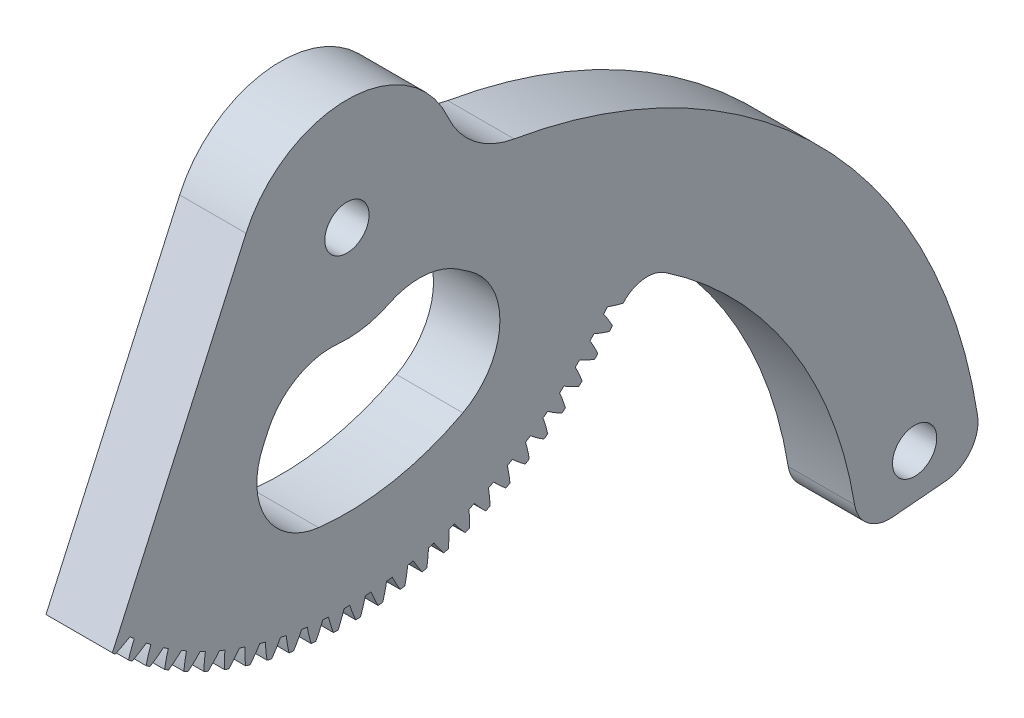
from build123d import *

# Parameters (mm, degrees)
BASPROSKE_W             = 12.7
BASPROSKE_H             = 49
TOOTHCUT_DEPTH          = 71.450621005
TEETHCUTS_COUNT         = 96
TEETHCUTS_ANGLE         = 356.25
BORSKE_R                = 0.4
BORE_DEPTH              = 50.0000508
CORTAR_EXTRUIR1_DEPTH   = 71.427720324
SALIENTE_EXTRUIR1_DEPTH = 12.7
CROQUIS4_R              = 3.175
CORTAR_EXTRUIR2_DEPTH   = 119.085472642
CROQUIS5_R              = 5
CORTAR_EXTRUIR3_DEPTH   = 6
CORTAR_EXTRUIR4_REACH   = 120.085
CORTAR_EXTRUIR5_DEPTH   = 1.5875


with BuildPart() as part:
    # BasProSke → Base-Revolve (revolve)
    with BuildSketch(Plane(origin=(0, 0, 0), x_dir=(1, 0, 0), z_dir=(0, 1, 0)), mode=Mode.PRIVATE) as base_revolve_sk:
        with Locations((6.35, 24.5)):
            Rectangle(BASPROSKE_W, BASPROSKE_H)
    revolve(base_revolve_sk.sketch.rotate(Axis((-10, 0, 0), (1, 0, 0)), 180), axis=Axis((-10, 0, 0), (1, 0, 0)))

    # TooCutSke → ToothCut (cut, through all)
    with BuildSketch(Plane(origin=(0, 0, 0), x_dir=(0, 0, -1), z_dir=(1, 0, 0))):
        with BuildLine():
            ThreePointArc((0.415666164, 46.747152027), (0, 46.749), (-0.415666164, 46.747152027))
            ThreePointArc((-0.415666164, 46.747152027), (-0.812912529, 47.891564186), (-1.28153738, 49.008647269))
            ThreePointArc((-1.28153738, 49.008647269), (0, 49.0254), (1.28153738, 49.008647269))
            ThreePointArc((1.28153738, 49.008647269), (0.812912529, 47.891564186), (0.415666164, 46.747152027))
        make_face()
    toothcut = extrude(amount=TOOTHCUT_DEPTH, mode=Mode.SUBTRACT)

    # TeethCuts: ToothCut ×96 about axis
    teethcuts_axis = Axis((-10, 0, 0), (1, 0, 0))
    for i in range(1, TEETHCUTS_COUNT):
        add(toothcut.rotate(teethcuts_axis, i * TEETHCUTS_ANGLE / (TEETHCUTS_COUNT - 1)), mode=Mode.SUBTRACT)

    # BorSke → Bore (cut, symmetric)
    with BuildSketch(Plane(origin=(0, 0, 0), x_dir=(0, 0, -1), z_dir=(1, 0, 0))):
        with Locations(Location((0, 0, 0), (0, 0, 180))):
            Circle(BORSKE_R)
    extrude(amount=BORE_DEPTH, both=True, mode=Mode.SUBTRACT)

    # Croquis2 → Cortar-Extruir1 (cut, through all)
    with BuildSketch(Plane(origin=(12.7, 0, 0), x_dir=(0, 0, -1), z_dir=(1, 0, 0))):
        with BuildLine():
            ThreePointArc((23.984655986, -0.583157257), (36.524600052, -3.793553196), (48.395867777, -8.953964212))
            ThreePointArc((48.395867777, -8.953964212), (-15.236757781, 47.277477286), (-33.647532421, -35.62083045))
            Line((-33.647532421, -35.62083045), (-14.472949427, 6.922987037))
            ThreePointArc((-14.472949427, 6.922987037), (0.063742892, 16.274872026), (14.524865824, 6.806551162))
            ThreePointArc((14.524865824, 6.806551162), (18.326573639, 1.923496246), (23.984655986, -0.583157257))
        make_face()
    extrude(amount=-CORTAR_EXTRUIR1_DEPTH, mode=Mode.SUBTRACT)

    # Croquis3 → Saliente-Extruir1 (add, through all)
    with BuildSketch(Plane(origin=(12.7, 0, 0), x_dir=(0, 0, -1), z_dir=(1, 0, 0))):
        with BuildLine():
            Line((78.291342391, -74.718112999), (85.901159176, -74.052340298))
            ThreePointArc((85.901159176, -74.052340298), (89.456654772, -72.12542661), (90.47830187, -68.212527108))
            ThreePointArc((90.47830187, -68.212527108), (68.118235351, -23.693910917), (23.984655986, -0.583157257))
            Line((23.984655986, -0.583157257), (26.101585902, -24.779776923))
            Line((26.101585902, -24.779776923), (39.634428828, -28.811665198))
            ThreePointArc((39.634428828, -28.811665198), (42.509448117, -27.287465547), (45.67542899, -28.039453308))
            ThreePointArc((45.67542899, -28.039453308), (63.643556946, -46.447865582), (72.834621498, -70.473843129))
            ThreePointArc((72.834621498, -70.473843129), (74.729702565, -73.667298489), (78.291342391, -74.718112999))
        make_face()
    extrude(amount=-SALIENTE_EXTRUIR1_DEPTH)

    # Croquis4 → Cortar-Extruir2 (cut, through all)
    with BuildSketch(Plane(origin=(12.7, 0, 0), x_dir=(0, 0, -1), z_dir=(1, 0, 0))):
        with Locations((0, 0.4)):
            Circle(CROQUIS4_R)
        with Locations((81.443110483, -68.068113052)):
            Circle(CROQUIS4_R)
    extrude(amount=-CORTAR_EXTRUIR2_DEPTH, mode=Mode.SUBTRACT)

    # Croquis5 → Cortar-Extruir3 (cut)
    with BuildSketch(Plane(origin=(0, 0, 0), x_dir=(0, 0, -1), z_dir=(1, 0, 0))):
        with Locations((81.443110483, -68.068113052)):
            Circle(CROQUIS5_R)
    extrude(amount=CORTAR_EXTRUIR3_DEPTH, mode=Mode.SUBTRACT)

    # Croquis7 → Cortar-Extruir4 (cut, up to next)
    with BuildSketch(Plane(origin=(12.7, 0, 0), x_dir=(0, 0, -1), z_dir=(1, 0, 0)), mode=Mode.PRIVATE) as cortar_extruir4_sk1:
        with BuildLine():
            Line((-12.043509039, -20.805573528), (-11.34750433, -19.261305404))
            ThreePointArc((-11.34750433, -19.261305404), (-7.259201746, -14.726545988), (-1.296355861, -13.414017916))
            ThreePointArc((-1.296355861, -13.414017916), (2.472528728, -13.252627263), (6.05863919, -12.082007878))
            ThreePointArc((6.05863919, -12.082007878), (11.144271121, -11.104114667), (16.037079993, -12.801273654))
            Line((16.037079993, -12.801273654), (17.558094048, -13.832517981))
            ThreePointArc((17.558094048, -13.832517981), (21.931785996, -22.648631071), (16.634261829, -30.942560718))
            ThreePointArc((16.634261829, -30.942560718), (6.576209725, -34.468441958), (-4.075170629, -34.848372491))
            ThreePointArc((-4.075170629, -34.848372491), (-11.624054462, -29.849707406), (-12.043509039, -20.805573528))
        make_face()
    cortar_extruir4_tool1 = extrude(cortar_extruir4_sk1.sketch, amount=-CORTAR_EXTRUIR4_REACH, mode=Mode.PRIVATE) & part.part
    add(cortar_extruir4_tool1.solids().sort_by_distance((12.7, -23.348546, -4.438761))[0], mode=Mode.SUBTRACT)

    # Croquis11 → Cortar-Extruir5 (cut)
    with BuildSketch(Plane(origin=(12.7, 0, 0), x_dir=(0, 0, -1), z_dir=(1, 0, 0))):
        with BuildLine():
            Line((78.291342391, -74.718112999), (85.901159176, -74.052340298))
            ThreePointArc((85.901159176, -74.052340298), (89.456654772, -72.12542661), (90.47830187, -68.212527108))
            ThreePointArc((90.47830187, -68.212527108), (68.118235351, -23.693910917), (23.984655986, -0.583157257))
            ThreePointArc((23.984655986, -0.583157257), (18.326573639, 1.923496246), (14.524865824, 6.806551162))
            ThreePointArc((14.524865824, 6.806551162), (0.063742892, 16.274872026), (-14.472949427, 6.922987037))
            Line((-14.472949427, 6.922987037), (-33.647532421, -35.62083045))
            ThreePointArc((-33.647532421, -35.62083045), (-33.450270144, -35.806136727), (-33.251987351, -35.990350613))
            ThreePointArc((-33.251987351, -35.990350613), (-32.176077274, -35.46435344), (-31.135053426, -34.872302035))
            ThreePointArc((-31.135053426, -34.872302035), (-30.82375751, -35.14775916), (-30.510024688, -35.420437526))
            ThreePointArc((-30.510024688, -35.420437526), (-30.961130133, -36.529833486), (-31.342192881, -37.665195411))
            ThreePointArc((-31.342192881, -37.665195411), (-31.085270924, -37.877512215), (-30.826910741, -38.088076535))
            ThreePointArc((-30.826910741, -38.088076535), (-29.787706131, -37.492837677), (-28.78763321, -36.833967682))
            ThreePointArc((-28.78763321, -36.833967682), (-28.458988045, -37.088475305), (-28.12809293, -37.340050738))
            ThreePointArc((-28.12809293, -37.340050738), (-28.505674557, -38.476575104), (-28.811665198, -39.634428828))
            ThreePointArc((-28.811665198, -39.634428828), (-28.541407147, -39.829487545), (-28.269828567, -40.022703467))
            ThreePointArc((-28.269828567, -40.022703467), (-27.271779458, -39.360771828), (-26.316939929, -38.637904625))
            ThreePointArc((-26.316939929, -38.637904625), (-25.972352823, -38.870372906), (-25.62571236, -39.09976812))
            ThreePointArc((-25.62571236, -39.09976812), (-25.928153306, -40.25855412), (-26.15776154, -41.433941536))
            ThreePointArc((-26.15776154, -41.433941536), (-25.875324682, -41.610906895), (-25.591690647, -41.785947037))
            ThreePointArc((-25.591690647, -41.785947037), (-24.639070838, -41.06015711), (-23.733553471, -40.276388128))
            ThreePointArc((-23.733553471, -40.276388128), (-23.3745, -40.485821602), (-23.013598556, -40.692054292))
            ThreePointArc((-23.013598556, -40.692054292), (-23.239603721, -41.868139827), (-23.391846332, -43.056027745))
            ThreePointArc((-23.391846332, -43.056027745), (-23.098440104, -43.214141953), (-22.803965179, -43.370256768))
            ThreePointArc((-22.803965179, -43.370256768), (-21.900853935, -42.583716496), (-21.048536294, -41.742401954))
            ThreePointArc((-21.048536294, -41.742401954), (-20.676553979, -41.927903794), (-20.302936989, -42.110090841))
            ThreePointArc((-20.302936989, -42.110090841), (-20.451538586, -43.298439731), (-20.525763647, -44.493741433))
            ThreePointArc((-20.525763647, -44.493741433), (-20.22264446, -44.632327421), (-19.918589631, -44.768848401))
            ThreePointArc((-19.918589631, -44.768848401), (-19.068854212, -43.92492587), (-18.273386052, -43.029668407))
            ThreePointArc((-18.273386052, -43.029668407), (-17.89006778, -43.190444265), (-17.50533513, -43.347805515))
            ThreePointArc((-17.50533513, -43.347805515), (-17.575896823, -44.543329069), (-17.57178649, -45.74092609))
            ThreePointArc((-17.57178649, -45.74092609), (-17.260252348, -45.859390411), (-16.947919624, -45.975732951))
            ThreePointArc((-16.947919624, -45.975732951), (-16.155198728, -45.078041968), (-15.419986367, -44.132675213))
            ThreePointArc((-15.419986367, -44.132675213), (-15.026973563, -44.268036624), (-14.632772738, -44.399898232))
            ThreePointArc((-14.632772738, -44.399898232), (-14.624992371, -45.597477033), (-14.542564246, -46.792241078))
            ThreePointArc((-14.542564246, -46.792241078), (-14.223949185, -46.890076451), (-13.904676024, -46.985742355))
            ThreePointArc((-13.904676024, -46.985742355), (-13.172364203, -46.038126971), (-12.500555932, -45.046699129))
            ThreePointArc((-12.500555932, -45.046699129), (-12.099531539, -45.156066453), (-11.697550566, -45.261863768))
            ThreePointArc((-11.697550566, -45.261863768), (-11.611461457, -46.456369601), (-11.45106851, -47.643184507))
            ThreePointArc((-11.45106851, -47.643184507), (-11.126736889, -47.719971985), (-10.801890466, -47.794551597))
            ThreePointArc((-10.801890466, -47.794551597), (-10.133123593, -46.801069645), (-9.527596197, -45.767826163))
            ThreePointArc((-9.527596197, -45.767826163), (-9.120277464, -45.850731074), (-8.712237687, -45.930011055))
            ThreePointArc((-8.712237687, -45.930011055), (-8.548208482, -47.116328862), (-8.31053754, -48.290112506))
            ThreePointArc((-8.31053754, -48.290112506), (-7.981878196, -48.345523272), (-7.652849554, -48.398697231))
            ThreePointArc((-7.652849554, -48.398697231), (-7.050491391, -47.363602954), (-6.513837834, -46.292968339))
            ThreePointArc((-6.513837834, -46.292968339), (-6.10196896, -46.349055824), (-5.689617669, -46.401478983))
            ThreePointArc((-5.689617669, -46.401478983), (-5.448350766, -47.574528769), (-5.134419572, -48.730254829))
            ThreePointArc((-5.134419572, -48.730254829), (-4.802839876, -48.764051607), (-4.471037966, -48.795592214))
            ThreePointArc((-4.471037966, -48.795592214), (-3.937667903, -47.723318044), (-3.472186216, -46.619876918))
            ThreePointArc((-3.472186216, -46.619876918), (-3.057530888, -46.648906802), (-2.642633834, -46.674248654))
            ThreePointArc((-2.642633834, -46.674248654), (-2.325162376, -47.82900724), (-1.936315232, -48.961726719))
            ThreePointArc((-1.936315232, -48.961726719), (-1.603235058, -48.973764786), (-1.270080708, -48.983536979))
            ThreePointArc((-1.270080708, -48.983536979), (-0.807982717, -47.87867456), (-0.415666164, -46.747152027))
            ThreePointArc((-0.415666164, -46.747152027), (0, -46.749), (0.415666164, -46.747152027))
            ThreePointArc((0.415666164, -46.747152027), (0.807982717, -47.87867456), (1.270080708, -48.983536979))
            ThreePointArc((1.270080708, -48.983536979), (1.603235058, -48.973764786), (1.936315232, -48.961726719))
            ThreePointArc((1.936315232, -48.961726719), (2.325162376, -47.82900724), (2.642633834, -46.674248654))
            ThreePointArc((2.642633834, -46.674248654), (3.057530888, -46.648906802), (3.472186216, -46.619876918))
            ThreePointArc((3.472186216, -46.619876918), (3.937667903, -47.723318044), (4.471037966, -48.795592214))
            ThreePointArc((4.471037966, -48.795592214), (4.802839876, -48.764051607), (5.134419572, -48.730254829))
            ThreePointArc((5.134419572, -48.730254829), (5.448350766, -47.574528769), (5.689617669, -46.401478983))
            ThreePointArc((5.689617669, -46.401478983), (6.10196896, -46.349055824), (6.513837834, -46.292968339))
            ThreePointArc((6.513837834, -46.292968339), (7.050491391, -47.363602954), (7.652849554, -48.398697231))
            ThreePointArc((7.652849554, -48.398697231), (7.981878196, -48.345523272), (8.31053754, -48.290112506))
            ThreePointArc((8.31053754, -48.290112506), (8.548208482, -47.116328862), (8.712237687, -45.930011055))
            ThreePointArc((8.712237687, -45.930011055), (9.120277464, -45.850731074), (9.527596197, -45.767826163))
            ThreePointArc((9.527596197, -45.767826163), (10.133123593, -46.801069645), (10.801890466, -47.794551597))
            ThreePointArc((10.801890466, -47.794551597), (11.126736889, -47.719971985), (11.45106851, -47.643184507))
            ThreePointArc((11.45106851, -47.643184507), (11.611461457, -46.456369601), (11.697550566, -45.261863768))
            ThreePointArc((11.697550566, -45.261863768), (12.099531539, -45.156066453), (12.500555932, -45.046699129))
            ThreePointArc((12.500555932, -45.046699129), (13.172364203, -46.038126971), (13.904676024, -46.985742355))
            ThreePointArc((13.904676024, -46.985742355), (14.223949185, -46.890076451), (14.542564246, -46.792241078))
            ThreePointArc((14.542564246, -46.792241078), (14.624992371, -45.597477033), (14.632772738, -44.399898232))
            ThreePointArc((14.632772738, -44.399898232), (15.026973563, -44.268036624), (15.419986367, -44.132675213))
            ThreePointArc((15.419986367, -44.132675213), (16.155198728, -45.078041968), (16.947919624, -45.975732951))
            ThreePointArc((16.947919624, -45.975732951), (17.260252348, -45.859390411), (17.57178649, -45.74092609))
            ThreePointArc((17.57178649, -45.74092609), (17.575896823, -44.543329069), (17.50533513, -43.347805515))
            ThreePointArc((17.50533513, -43.347805515), (17.89006778, -43.190444265), (18.273386052, -43.029668407))
            ThreePointArc((18.273386052, -43.029668407), (19.068854212, -43.92492587), (19.918589631, -44.768848401))
            ThreePointArc((19.918589631, -44.768848401), (20.22264446, -44.632327421), (20.525763647, -44.493741433))
            ThreePointArc((20.525763647, -44.493741433), (20.451538586, -43.298439731), (20.302936989, -42.110090841))
            ThreePointArc((20.302936989, -42.110090841), (20.676553979, -41.927903794), (21.048536294, -41.742401954))
            ThreePointArc((21.048536294, -41.742401954), (21.900853935, -42.583716496), (22.803965179, -43.370256768))
            ThreePointArc((22.803965179, -43.370256768), (23.098440104, -43.214141953), (23.391846332, -43.056027745))
            ThreePointArc((23.391846332, -43.056027745), (23.239603721, -41.868139827), (23.013598556, -40.692054292))
            ThreePointArc((23.013598556, -40.692054292), (23.3745, -40.485821602), (23.733553471, -40.276388128))
            ThreePointArc((23.733553471, -40.276388128), (24.639070838, -41.06015711), (25.591690647, -41.785947037))
            ThreePointArc((25.591690647, -41.785947037), (25.875324682, -41.610906895), (26.15776154, -41.433941536))
            ThreePointArc((26.15776154, -41.433941536), (25.928153306, -40.25855412), (25.62571236, -39.09976812))
            ThreePointArc((25.62571236, -39.09976812), (25.972352823, -38.870372906), (26.316939929, -38.637904625))
            ThreePointArc((26.316939929, -38.637904625), (27.271779458, -39.360771828), (28.269828567, -40.022703467))
            ThreePointArc((28.269828567, -40.022703467), (28.541407147, -39.829487545), (28.811665198, -39.634428828))
            ThreePointArc((28.811665198, -39.634428828), (28.505674557, -38.476575104), (28.12809293, -37.340050738))
            ThreePointArc((28.12809293, -37.340050738), (28.458988045, -37.088475305), (28.78763321, -36.833967682))
            ThreePointArc((28.78763321, -36.833967682), (29.787706131, -37.492837677), (30.826910741, -38.088076535))
            ThreePointArc((30.826910741, -38.088076535), (31.085270924, -37.877512215), (31.342192881, -37.665195411))
            ThreePointArc((31.342192881, -37.665195411), (30.961130133, -36.529833486), (30.510024688, -35.420437526))
            ThreePointArc((30.510024688, -35.420437526), (30.82375751, -35.14775916), (31.135053426, -34.872302035))
            ThreePointArc((31.135053426, -34.872302035), (32.176077274, -35.46435344), (33.251987351, -35.990350613))
            ThreePointArc((33.251987351, -35.990350613), (33.496022799, -35.763339562), (33.738508484, -35.534673845))
            ThreePointArc((33.738508484, -35.534673845), (33.284005397, -34.426665513), (32.761307836, -33.349148563))
            ThreePointArc((32.761307836, -33.349148563), (33.056534914, -33.056534914), (33.349148563, -32.761307836))
            ThreePointArc((33.349148563, -32.761307836), (34.426665513, -33.284005397), (35.534673845, -33.738508484))
            ThreePointArc((35.534673845, -33.738508484), (35.763339562, -33.496022799), (35.990350613, -33.251987351))
            ThreePointArc((35.990350613, -33.251987351), (35.46435344, -32.176077274), (34.872302035, -31.135053426))
            ThreePointArc((34.872302035, -31.135053426), (35.14775916, -30.82375751), (35.420437526, -30.510024688))
            ThreePointArc((35.420437526, -30.510024688), (36.529833486, -30.961130133), (37.665195411, -31.342192881))
            ThreePointArc((37.665195411, -31.342192881), (37.877512215, -31.085270924), (38.088076535, -30.826910741))
            ThreePointArc((38.088076535, -30.826910741), (37.492837677, -29.787706131), (36.833967682, -28.78763321))
            ThreePointArc((36.833967682, -28.78763321), (37.088475305, -28.458988045), (37.340050738, -28.12809293))
            ThreePointArc((37.340050738, -28.12809293), (38.476575104, -28.505674557), (39.634428828, -28.811665198))
            ThreePointArc((39.634428828, -28.811665198), (42.509448117, -27.287465547), (45.67542899, -28.039453308))
            ThreePointArc((45.67542899, -28.039453308), (63.643556946, -46.447865582), (72.834621498, -70.473843129))
            ThreePointArc((72.834621498, -70.473843129), (74.729702565, -73.667298489), (78.291342391, -74.718112999))
        make_face()
    cortar_extruir5 = extrude(amount=-CORTAR_EXTRUIR5_DEPTH, mode=Mode.SUBTRACT)

    # Simetría1: Cortar-Extruir5 across plane
    add(cortar_extruir5.mirror(Plane(origin=(6.35, 0, 0), x_dir=(0, 0, 1), z_dir=(1, 0, 0))), mode=Mode.SUBTRACT)


solid = part.part
